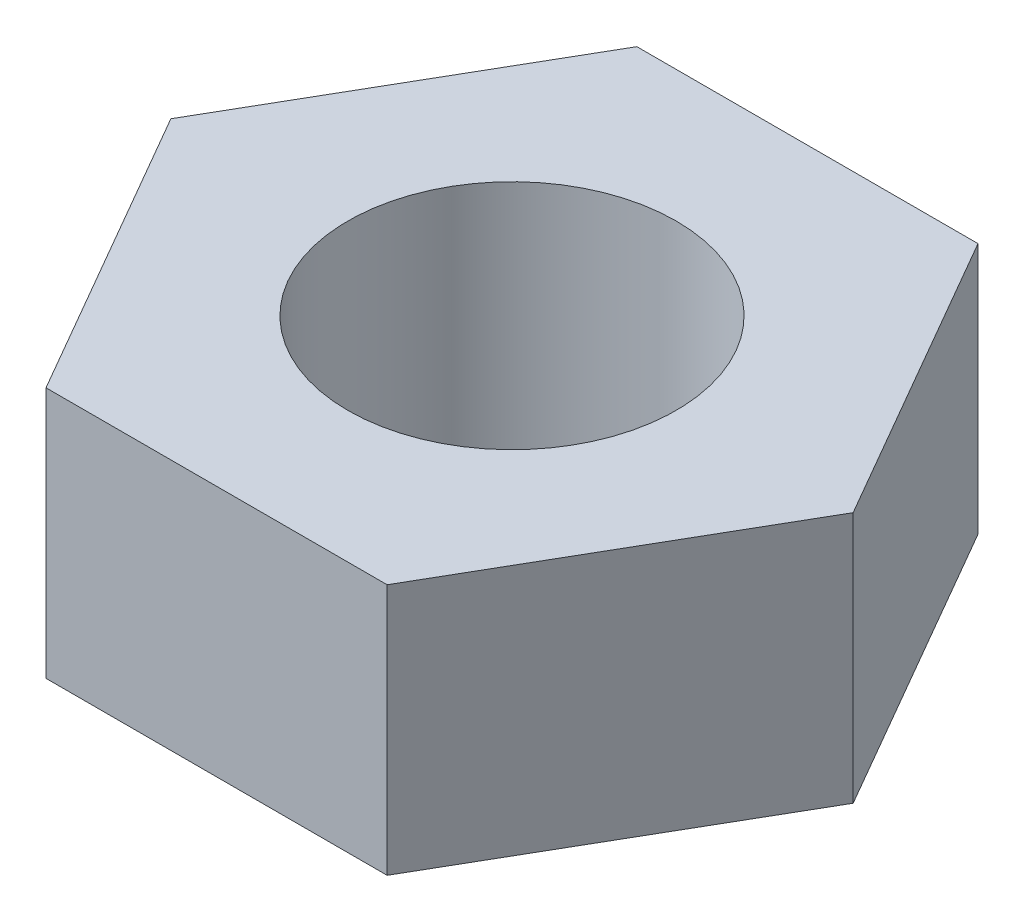
from build123d import *

# Parameters (mm, degrees)
SKETCH_1_R      = 1.5
EXTRUDE_1_DEPTH = 2.3


with BuildPart() as part:
    # 草图1 → 凸台-拉伸1 (new body)
    with BuildSketch(Plane(origin=(0, 0, 0), x_dir=(1, 0, 0), z_dir=(0, 1, 0))):
        Polygon((3.117691454, 0), (1.558845727, 2.7), (-1.558845727, 2.7), (-3.117691454, 0), (-1.558845727, -2.7), (1.558845727, -2.7), align=None)
        Circle(SKETCH_1_R, mode=Mode.SUBTRACT)
    extrude(amount=EXTRUDE_1_DEPTH)


solid = part.part
